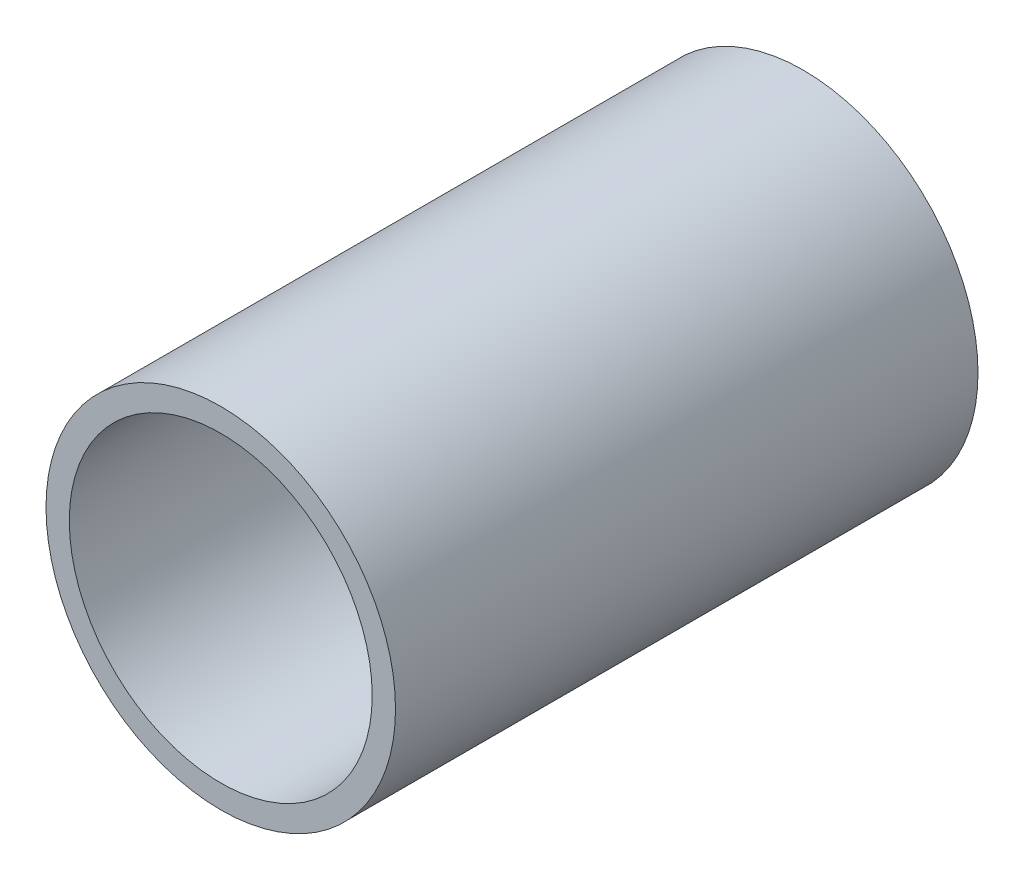
from build123d import *

# Parameters (mm, degrees)
ESQUISSE1_R        = 15
ESQUISSE1_R_2      = 13
BOSS_EXTRU_1_DEPTH = 50


with BuildPart() as part:
    # Esquisse1 → Boss.-Extru.1 (new body)
    with BuildSketch(Plane.XY):
        Circle(ESQUISSE1_R)
        Circle(ESQUISSE1_R_2, mode=Mode.SUBTRACT)
    extrude(amount=BOSS_EXTRU_1_DEPTH)


solid = part.part
